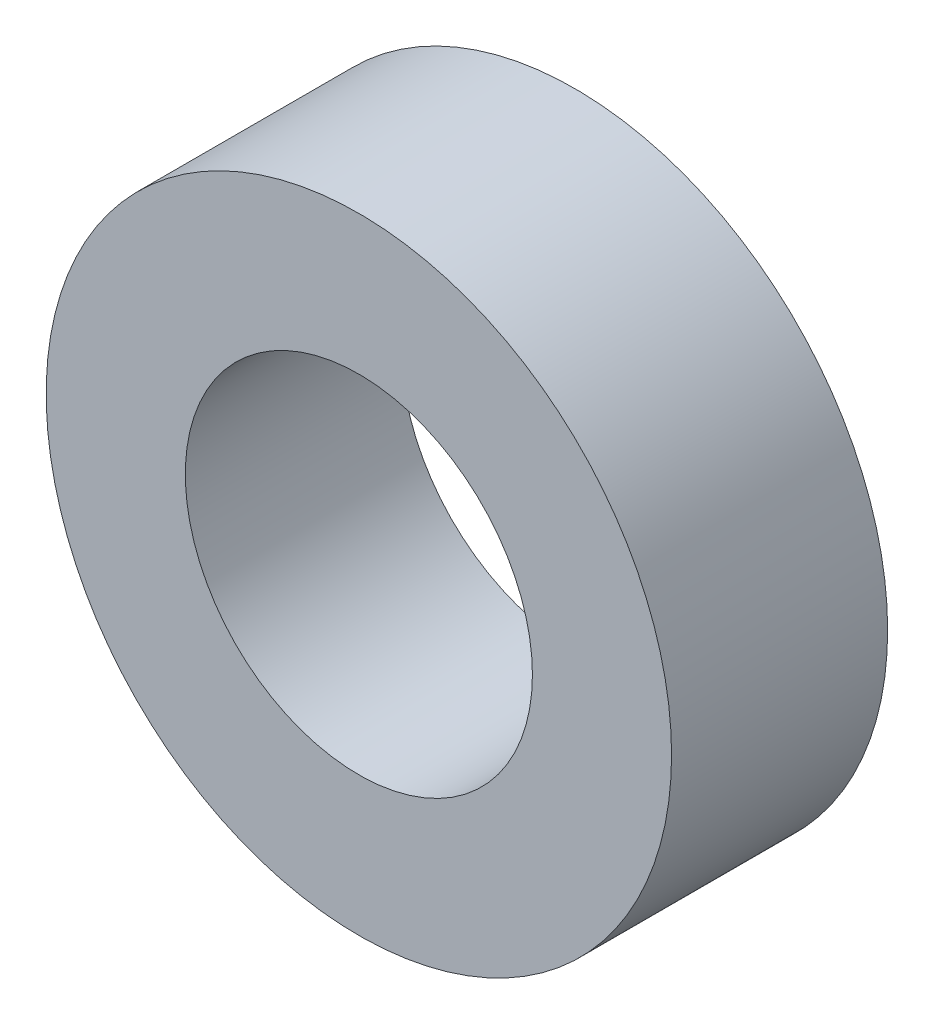
from build123d import *

# Parameters (mm, degrees)
SKETCH1_R           = 10
SKETCH1_R_2         = 5.55
BOSS_EXTRUDE1_DEPTH = 6.91


with BuildPart() as part:
    # Sketch1 → Boss-Extrude1 (new body)
    with BuildSketch(Plane.XY):
        with Locations((11.298610039, 11.872509653)):
            Circle(SKETCH1_R)
        with Locations((11.298610039, 11.872509653)):
            Circle(SKETCH1_R_2, mode=Mode.SUBTRACT)
    extrude(amount=BOSS_EXTRUDE1_DEPTH)


solid = part.part
